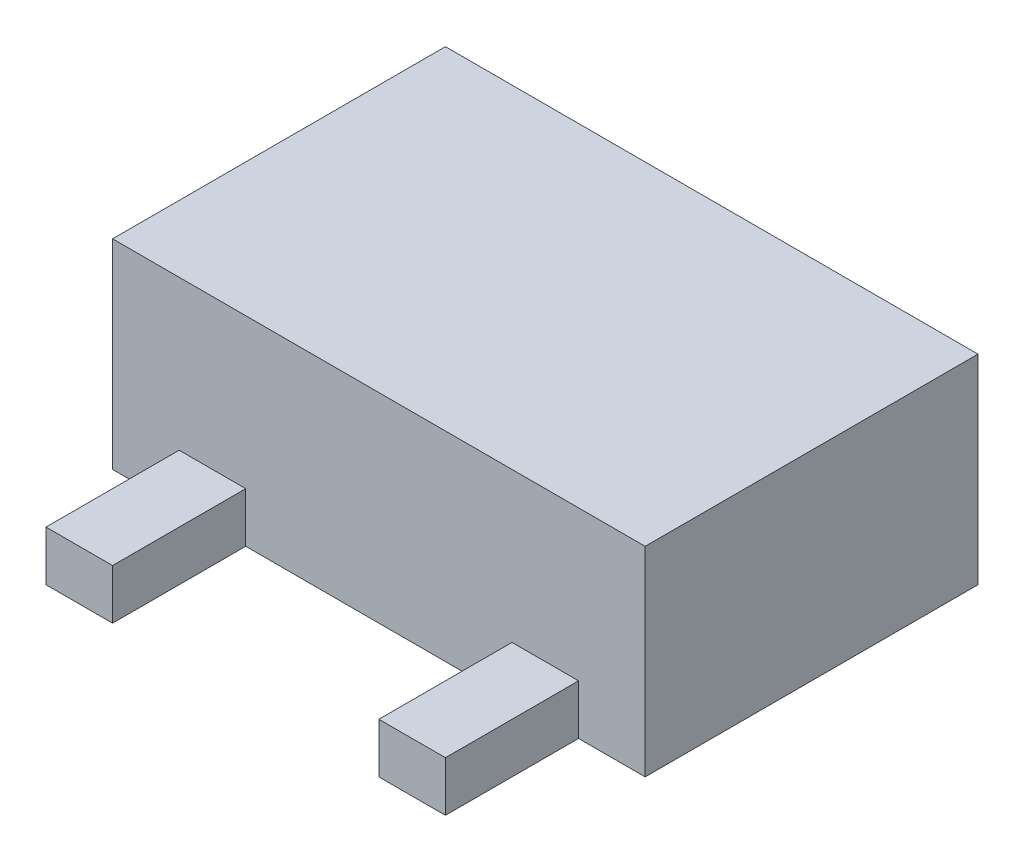
from build123d import *

# Parameters (mm, degrees)
BASES_W       = 1.6
BASES_H       = 1
BASE_DEPTH    = 0.6
LEGS_W        = 0.2
LEGS_H        = 0.4
LEG_DEPTH     = 0.15
SIDELEGS_W    = 0.2
SIDELEGS_H    = 0.4
SIDELEG_DEPTH = 0.15


with BuildPart() as part:
    # BaseS → Base (new body)
    with BuildSketch(Plane(origin=(0, 0, 0), x_dir=(1, 0, 0), z_dir=(0, 1, 0))):
        Rectangle(BASES_W, BASES_H)
    extrude(amount=BASE_DEPTH)

    # LegS → Leg (add)
    with BuildSketch(Plane(origin=(0, 0, 0), x_dir=(1, 0, 0), z_dir=(0, 1, 0))):
        with Locations((0, 0.7)):
            Rectangle(LEGS_W, LEGS_H)
    extrude(amount=LEG_DEPTH)

    # SideLegS → SideLeg (add)
    with BuildSketch(Plane(origin=(0, 0, 0), x_dir=(1, 0, 0), z_dir=(0, 1, 0))):
        with Locations((-0.5, -0.7)):
            Rectangle(SIDELEGS_W, SIDELEGS_H)
    sideleg = extrude(amount=SIDELEG_DEPTH)

    # SLHM: SideLeg across plane
    add(sideleg.mirror(Plane(origin=(0, 0, 0), x_dir=(0, 0, 1), z_dir=(1, 0, 0))))


solid = part.part
